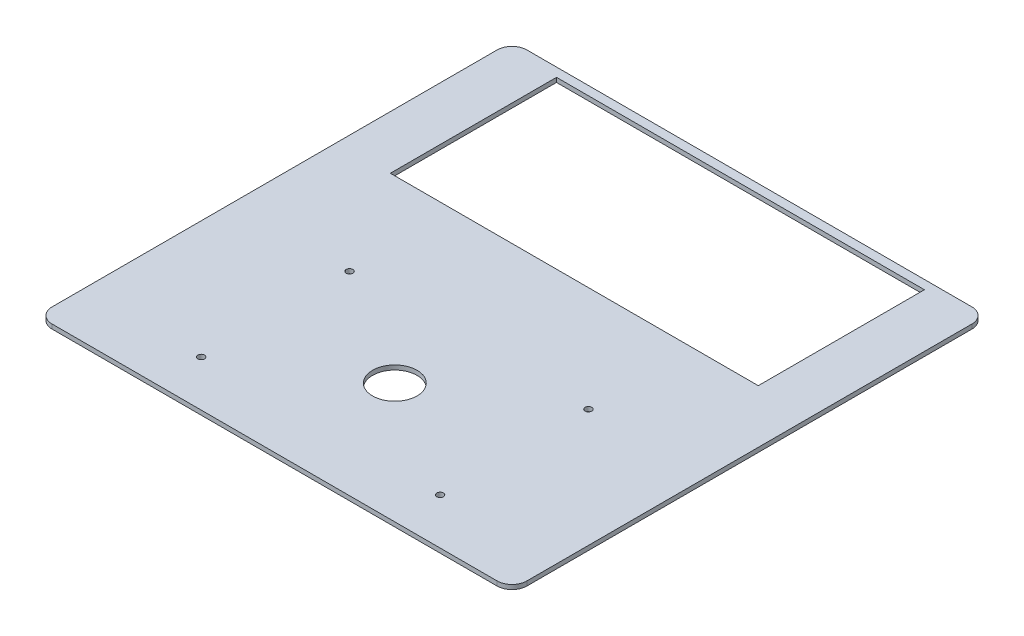
from build123d import *

# Parameters (mm, degrees)
SKETCH1_W           = 320
SKETCH1_H           = 320
SKETCH1_R           = 2.25
SKETCH1_R_2         = 15
SKETCH1_W_2         = 248
SKETCH1_H_2         = 112
BOSS_EXTRUDE1_DEPTH = 3
FILLET1_R           = 10


with BuildPart() as part:
    # Sketch1 → Boss-Extrude1 (new body)
    with BuildSketch(Plane(origin=(0, 0, 0), x_dir=(1, 0, 0), z_dir=(0, 1, 0))):
        with Locations((45.2, -56.43)):
            Rectangle(SKETCH1_W, SKETCH1_H)
        with Locations((-35.3, -85.43)):
            Circle(SKETCH1_R, mode=Mode.SUBTRACT)
        with Locations((125.7, -85.43)):
            Circle(SKETCH1_R, mode=Mode.SUBTRACT)
        with Locations((125.7, -185.43)):
            Circle(SKETCH1_R, mode=Mode.SUBTRACT)
        with Locations((-35.3, -185.43)):
            Circle(SKETCH1_R, mode=Mode.SUBTRACT)
        with Locations((45.2, -135.43)):
            Circle(SKETCH1_R_2, mode=Mode.SUBTRACT)
        with Locations((45.2, 41.57)):
            Rectangle(SKETCH1_W_2, SKETCH1_H_2, mode=Mode.SUBTRACT)
    extrude(amount=BOSS_EXTRUDE1_DEPTH)

    # Fillet1
    fillet1_edges = [part.edges().sort_by_distance(p)[0] for p in [
        (205.2, 1.5, 216.43),
        (-114.8, 1.5, 216.43),
        (-114.8, 1.5, -103.57),
        (205.2, 1.5, -103.57),
    ]]
    fillet(fillet1_edges, radius=FILLET1_R)


solid = part.part
